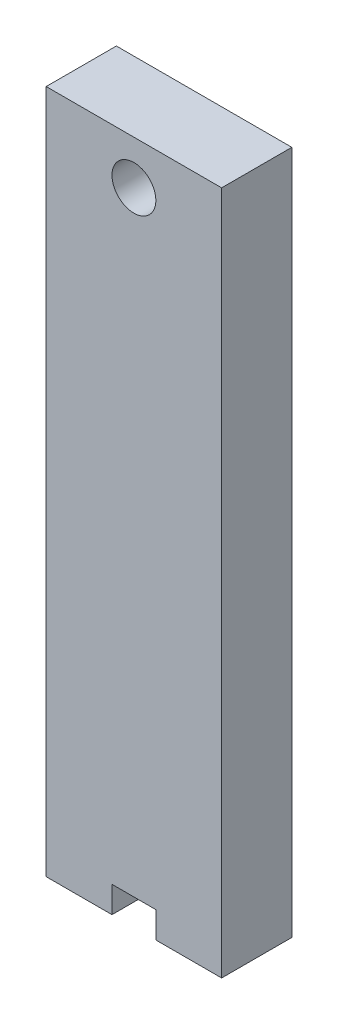
from build123d import *

# Parameters (mm, degrees)
SKETCH2_W               = 20
SKETCH2_H               = 8
SKETCH2_W_2             = 16
SKETCH2_H_2             = 4
BOSS_EXTRUDE2_DEPTH     = 65
CUT_EXTRUDE2_DEPTH      = 2
SKETCH5_W               = 7.5
SKETCH5_H               = 8
BOSS_EXTRUDE3_DEPTH     = 3
SKETCH6_W               = 20
SKETCH6_H               = 8
BOSS_EXTRUDE4_DEPTH     = 10
SKETCH7_R               = 2.5
CUT_EXTRUDE3_DEPTH      = 1
CUT_EXTRUDE3_DEPTH_BACK = 9


with BuildPart() as part:
    # Sketch2 → Boss-Extrude2 (new body)
    with BuildSketch(Plane(origin=(0, 0, 0), x_dir=(1, 0, 0), z_dir=(0, 1, 0))):
        Rectangle(SKETCH2_W, SKETCH2_H)
        Rectangle(SKETCH2_W_2, SKETCH2_H_2, mode=Mode.SUBTRACT)
    extrude(amount=BOSS_EXTRUDE2_DEPTH)

    # Sketch4 → Cut-Extrude2 (cut)
    with BuildSketch(Plane(origin=(0, 0, -4), x_dir=(-1, 0, 0), z_dir=(0, 0, -1))):
        Polygon((8, 60), (-8, 60), (-8, 57.5), (-2.5, 57.5), (-2.5, 0), (2.5, 0), (2.5, 57.5), (8, 57.5), align=None)
    extrude(amount=-CUT_EXTRUDE2_DEPTH, mode=Mode.SUBTRACT)

    # Sketch5 → Boss-Extrude3 (add)
    with BuildSketch(Plane.XZ):
        with Locations((-6.25, 0)):
            Rectangle(SKETCH5_W, SKETCH5_H)
        with Locations((6.25, 0)):
            Rectangle(SKETCH5_W, SKETCH5_H)
    extrude(amount=BOSS_EXTRUDE3_DEPTH)

    # Sketch6 → Boss-Extrude4 (add)
    with BuildSketch(Plane(origin=(0, 65, 0), x_dir=(1, 0, 0), z_dir=(0, 1, 0))):
        Rectangle(SKETCH6_W, SKETCH6_H)
    extrude(amount=BOSS_EXTRUDE4_DEPTH)

    # Sketch7 → Cut-Extrude3 (cut, two sides)
    with BuildSketch(Plane(origin=(0, 0, -4), x_dir=(-1, 0, 0), z_dir=(0, 0, -1))) as cut_extrude3_sk:
        with Locations((0, 70)):
            Circle(SKETCH7_R)
    extrude(amount=CUT_EXTRUDE3_DEPTH, mode=Mode.SUBTRACT)
    extrude(cut_extrude3_sk.sketch, amount=-CUT_EXTRUDE3_DEPTH_BACK, mode=Mode.SUBTRACT)


solid = part.part
